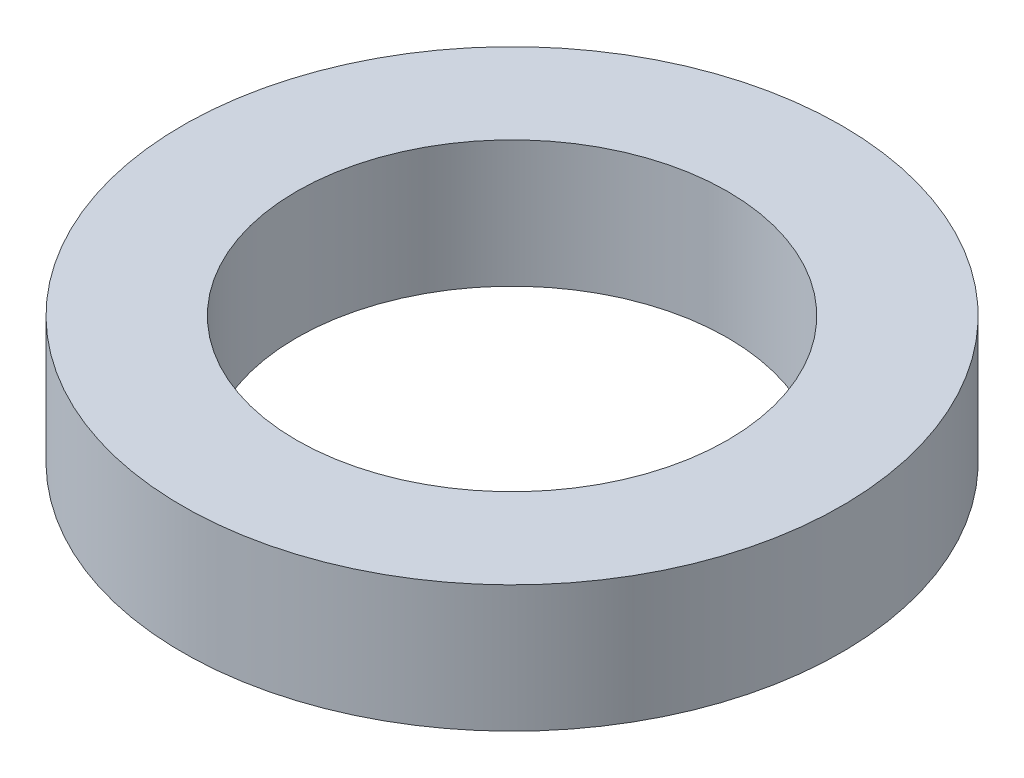
from build123d import *

# Parameters (mm, degrees)
SKETCH1_W = 4.5
SKETCH1_H = 5


with BuildPart() as part:
    # Sketch1 → Revolve1 (revolve)
    with BuildSketch(Plane.XY):
        with Locations((10.75, 2.5)):
            Rectangle(SKETCH1_W, SKETCH1_H)
    revolve(axis=Axis((0, 0, 0), (0, 1, 0)))


solid = part.part
